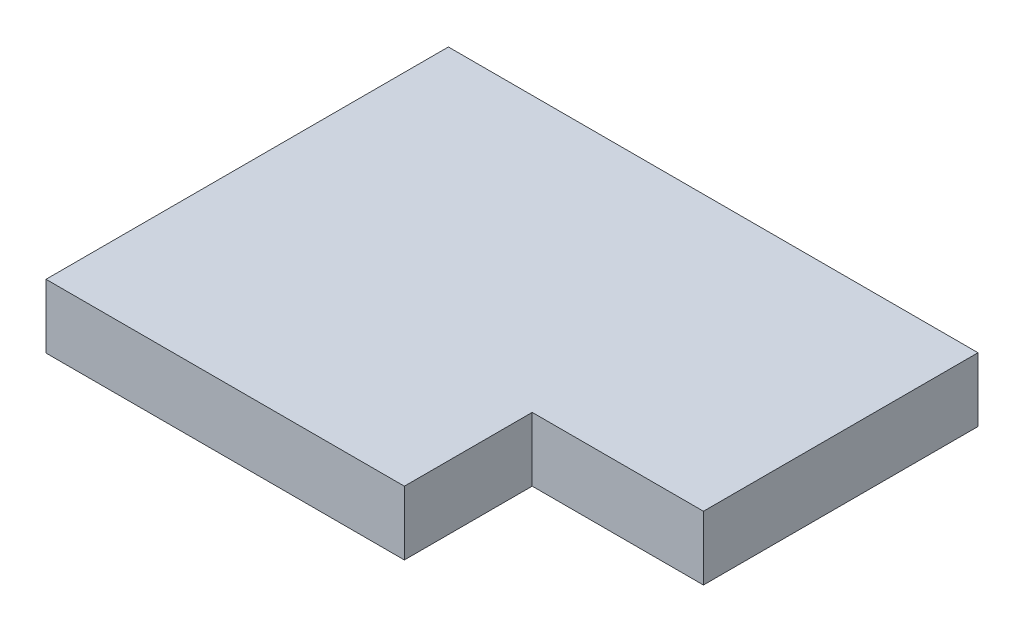
from build123d import *

# Parameters (mm, degrees)
SKETCH1_W           = 870
SKETCH1_H           = 661
BOSS_EXTRUDE1_DEPTH = 105
SKETCH2_W           = 281.3
SKETCH2_H           = 210
CUT_EXTRUDE1_DEPTH  = 106


with BuildPart() as part:
    # Sketch1 → Boss-Extrude1 (new body)
    with BuildSketch(Plane(origin=(0, 0, 0), x_dir=(1, 0, 0), z_dir=(0, 1, 0))):
        Rectangle(SKETCH1_W, SKETCH1_H)
    extrude(amount=BOSS_EXTRUDE1_DEPTH)

    # Sketch2 → Cut-Extrude1 (cut, through all)
    with BuildSketch(Plane(origin=(0, 105, 0), x_dir=(1, 0, 0), z_dir=(0, 1, 0))):
        with Locations((294.35, -225.5)):
            Rectangle(SKETCH2_W, SKETCH2_H)
    extrude(amount=-CUT_EXTRUDE1_DEPTH, mode=Mode.SUBTRACT)


solid = part.part
